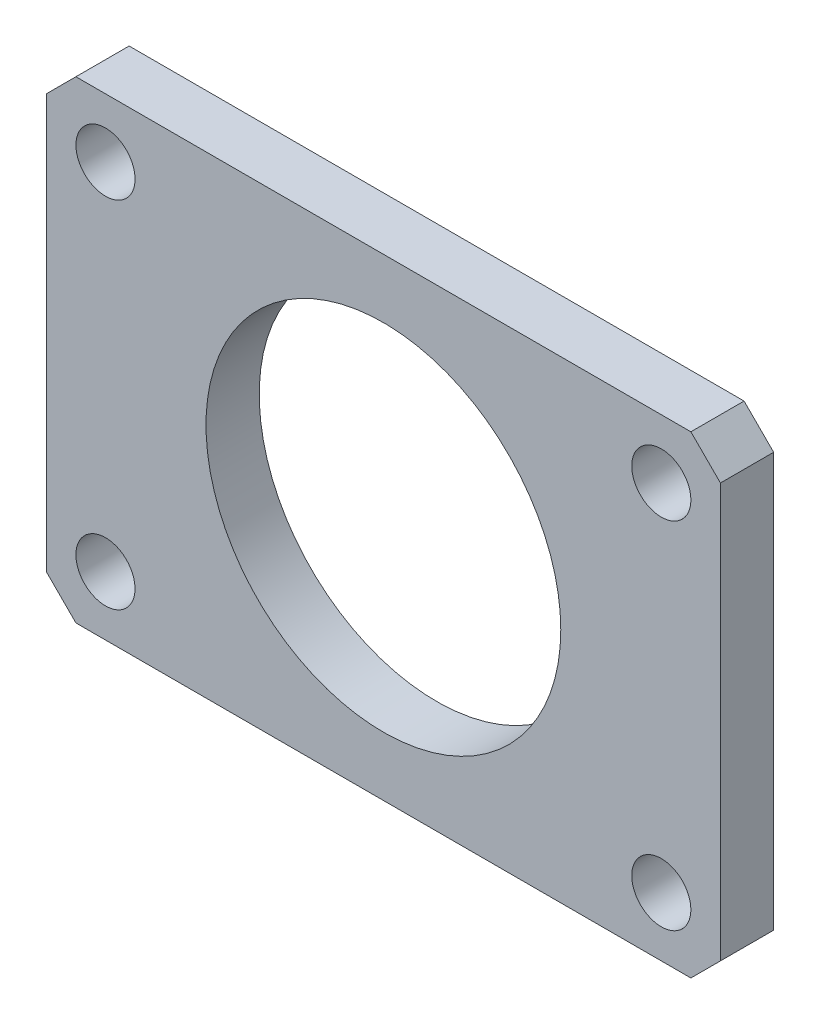
from build123d import *

# Parameters (mm, degrees)
SKETCH_1_W          = 28.5
SKETCH_1_H          = 20
SKETCH_1_R          = 2.5
EXTRUDE_1_DEPTH     = 4.5
CHAMFER_1_SIZE      = 2.5
SKETCH_2_R          = 15
CUT_EXTRUDE_1_DEPTH = 5.5


with BuildPart() as part:
    # Эскиз1 → Бобышка-Вытянуть1 (new body)
    with BuildSketch(Plane.XY):
        Rectangle(SKETCH_1_W, SKETCH_1_H)
        with Locations((9.25, 5)):
            Circle(SKETCH_1_R, mode=Mode.SUBTRACT)
    extrude(amount=EXTRUDE_1_DEPTH)

    # Фаска1
    chamfer_1_edges = [part.edges().sort_by_distance(p)[0] for p in [
        (14.25, 10, 2.25),
    ]]
    chamfer(chamfer_1_edges, length=CHAMFER_1_SIZE)

    # Зеркальное отражение1: part across plane


with BuildPart() as part_1:
    add(part.part)
    add(part.part.mirror(Plane(origin=(-14.25, -10, 4.5), x_dir=(0, 0, 1), z_dir=(0, 1, 0))))

    # Зеркальное отражение2: part across plane


with BuildPart() as part_2:
    add(part_1.part)
    add(part_1.part.mirror(Plane(origin=(-14.25, -10, 4.5), x_dir=(0, 0, 1), z_dir=(1, 0, 0))))

    # Эскиз2 → Вырез-Вытянуть1 (cut, through all)
    with BuildSketch(Plane.XY.offset(4.5)):
        with Locations((-14.25, -10)):
            Circle(SKETCH_2_R)
    extrude(amount=-CUT_EXTRUDE_1_DEPTH, mode=Mode.SUBTRACT)


solid = part_2.part
